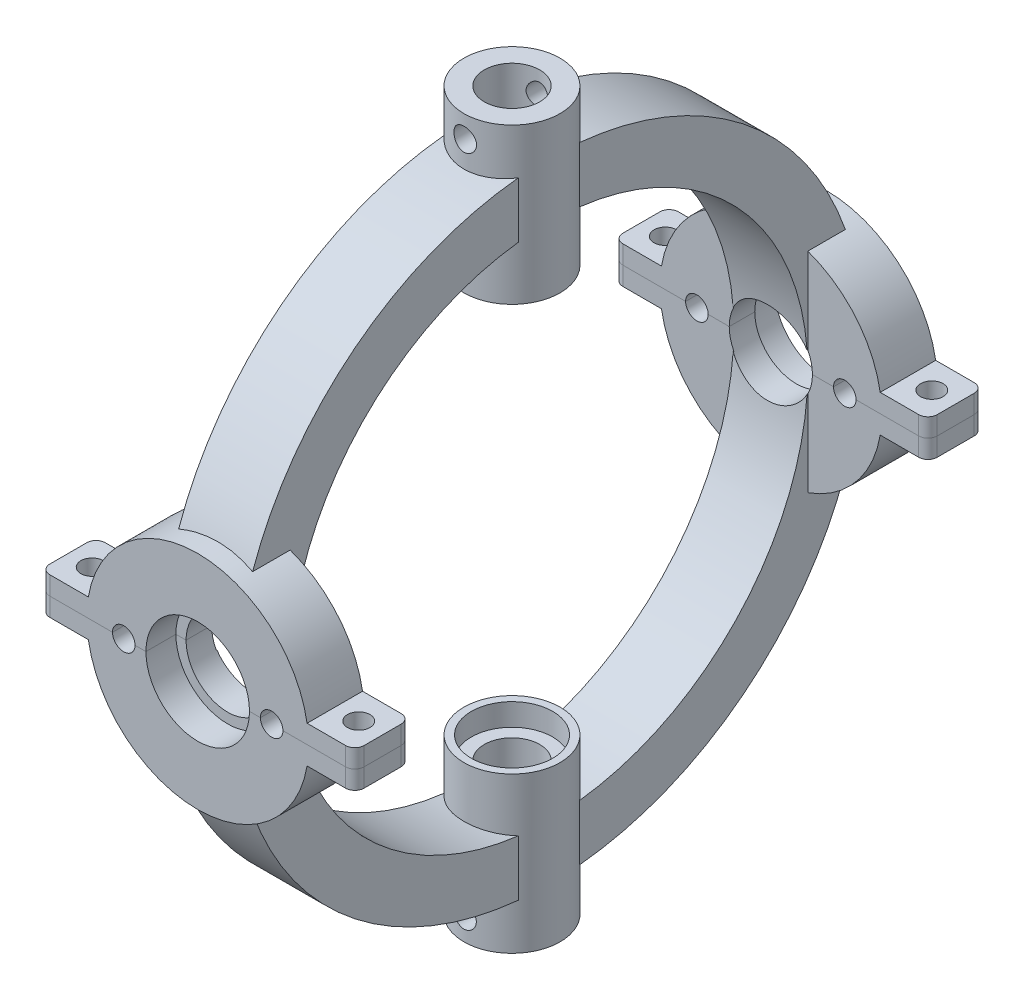
from build123d import *

# Parameters (mm, degrees)
SKETCH1_W                = 13
SKETCH1_H                = 150
SKETCH2_R                = 85
SKETCH2_R_2              = 70
BOSS_EXTRUDE1_DEPTH      = 10
BOSS_EXTRUDE1_DEPTH_BACK = 10
SKETCH3_R                = 30
BOSS_EXTRUDE2_DEPTH      = 15
CUT_EXTRUDE1_REACH       = 194.419
SKETCH4_R                = 11.25
SKETCH4_R_2              = 3.05
BOSS_EXTRUDE3_DEPTH      = 15
MIRROR3_COPY_1_DEPTH     = 15
SKETCH6_R                = 3.05
CUT_EXTRUDE2_DEPTH       = 10
MIRROR5_COPY_1_SKETCH_R  = 3.05
MIRROR5_COPY_1_DEPTH     = 10
FILLET1_R                = 2.5
SKETCH7_R                = 13
BOSS_EXTRUDE4_DEPTH      = 15
SKETCH10_R               = 14
CUT_EXTRUDE5_DEPTH       = 8.1
SKETCH12_R               = 13
CUT_EXTRUDE7_DEPTH       = 55
CUT_EXTRUDE7_DEPTH_BACK  = 55
SKETCH13_R               = 11
CUT_EXTRUDE8_DEPTH       = 6
SKETCH14_R               = 7.5
CUT_EXTRUDE9_DEPTH       = 175.204621196
SKETCH15_R               = 13
SKETCH15_R_2             = 7.5
BOSS_EXTRUDE6_DEPTH      = 12
SKETCH16_R               = 3
CUT_EXTRUDE10_DEPTH      = 136.794882217
CUT_EXTRUDE10_DEPTH_BACK = 136.794882217
SKETCH17_R               = 13
SKETCH17_R_2             = 7.5
BOSS_EXTRUDE7_DEPTH      = 12
SKETCH18_R               = 3.05
CUT_EXTRUDE11_DEPTH      = 136.794882217
CUT_EXTRUDE11_DEPTH_BACK = 136.794882217


with BuildPart() as part:
    # Sketch1 → Revolve1 (revolve)
    with BuildSketch(Plane(origin=(0, 0, 0), x_dir=(0, 0, -1), z_dir=(1, 0, 0))):
        with Locations((6.5, 0)):
            Rectangle(SKETCH1_W, SKETCH1_H)
    revolve(axis=Axis((0, -75, 0), (0, 1, 0)))

    # Sketch2 → Boss-Extrude1 (add, two sides)
    with BuildSketch(Plane(origin=(0, 0, 0), x_dir=(0, 0, -1), z_dir=(1, 0, 0))) as boss_extrude1_sk:
        Circle(SKETCH2_R)
        Circle(SKETCH2_R_2, mode=Mode.SUBTRACT)
    extrude(amount=BOSS_EXTRUDE1_DEPTH)
    extrude(boss_extrude1_sk.sketch, amount=-BOSS_EXTRUDE1_DEPTH_BACK)

    # Sketch3 → Boss-Extrude2 (add)
    with BuildSketch(Plane.XY.offset(85)):
        Circle(SKETCH3_R)
    boss_extrude2 = extrude(amount=-BOSS_EXTRUDE2_DEPTH)

    # Sketch4 → Cut-Extrude1 (cut, up to next)
    with BuildSketch(Plane.XY.offset(85), mode=Mode.PRIVATE) as cut_extrude1_sk1:
        Circle(SKETCH4_R)
    cut_extrude1_tool1 = extrude(cut_extrude1_sk1.sketch, amount=-CUT_EXTRUDE1_REACH, mode=Mode.PRIVATE) & part.part
    # Sketch4 → Cut-Extrude1 (cut, up to next)
    with BuildSketch(Plane.XY.offset(85), mode=Mode.PRIVATE) as cut_extrude1_sk2:
        with Locations((20, 0)):
            Circle(SKETCH4_R_2)
    cut_extrude1_tool2 = extrude(cut_extrude1_sk2.sketch, amount=-CUT_EXTRUDE1_REACH, mode=Mode.PRIVATE) & part.part
    # Sketch4 → Cut-Extrude1 (cut, up to next)
    with BuildSketch(Plane.XY.offset(85), mode=Mode.PRIVATE) as cut_extrude1_sk3:
        with Locations((-20, 0)):
            Circle(SKETCH4_R_2)
    cut_extrude1_tool3 = extrude(cut_extrude1_sk3.sketch, amount=-CUT_EXTRUDE1_REACH, mode=Mode.PRIVATE) & part.part
    cut_extrude1_1 = cut_extrude1_tool1.solids().sort_by_distance((0, 0, 85))[0]
    add(cut_extrude1_1, mode=Mode.SUBTRACT)
    cut_extrude1_2 = cut_extrude1_tool2.solids().sort_by_distance((20, 0, 85))[0]
    add(cut_extrude1_2, mode=Mode.SUBTRACT)
    cut_extrude1_3 = cut_extrude1_tool3.solids().sort_by_distance((-20, 0, 85))[0]
    add(cut_extrude1_3, mode=Mode.SUBTRACT)
    cut_extrude1 = cut_extrude1_1 + cut_extrude1_2 + cut_extrude1_3  # Cut-Extrude1 as one shape, for the pattern or mirror that repeats it

    # Mirror1: Boss-Extrude2, Cut-Extrude1 across plane
    add(boss_extrude2.mirror(Plane.XY))
    add(cut_extrude1.mirror(Plane.XY), mode=Mode.SUBTRACT)

    # Sketch5 → Boss-Extrude3 (add)
    with BuildSketch(Plane.XY.offset(85)):
        Polygon((-42.5, 0), (-42.5, 5), (-27.5, 5), (-27.5, -5), (-42.5, -5), align=None)
    boss_extrude3 = extrude(amount=-BOSS_EXTRUDE3_DEPTH)

    # Mirror2: Boss-Extrude3 across plane
    add(boss_extrude3.mirror(Plane(origin=(0, 0, 0), x_dir=(0, 0, 1), z_dir=(1, 0, 0))))

    # Mirror3: Boss-Extrude3 across plane
    add(boss_extrude3.mirror(Plane.XY))

    # Mirror3 copy 1 sketch → Mirror3 copy 1 (add)
    with BuildSketch(Plane(origin=(0, 0, -85), x_dir=(-1, 0, 0), z_dir=(0, 0, -1))):
        Polygon((-42.5, 0), (-42.5, 5), (-27.5, 5), (-27.5, -5), (-42.5, -5), align=None)
    extrude(amount=-MIRROR3_COPY_1_DEPTH)

    # Sketch6 → Cut-Extrude2 (cut)
    with BuildSketch(Plane(origin=(0, 5, 0), x_dir=(1, 0, 0), z_dir=(0, 1, 0))):
        with Locations(Location((-36.040199458, -77.5, 0), (0, 0, 180))):
            Circle(SKETCH6_R)
    cut_extrude2 = extrude(amount=-CUT_EXTRUDE2_DEPTH, mode=Mode.SUBTRACT)

    # Mirror4: Cut-Extrude2 across plane
    add(cut_extrude2.mirror(Plane(origin=(0, 0, 0), x_dir=(0, 0, 1), z_dir=(1, 0, 0))), mode=Mode.SUBTRACT)

    # Mirror5: Cut-Extrude2 across plane
    add(cut_extrude2.mirror(Plane.XY), mode=Mode.SUBTRACT)

    # Mirror5 copy 1 sketch → Mirror5 copy 1 (cut)
    with BuildSketch(Plane(origin=(0, 5, 0), x_dir=(-1, 0, 0), z_dir=(0, 1, 0))):
        with Locations(Location((-36.040199458, -77.5, 0), (0, 0, 180))):
            Circle(MIRROR5_COPY_1_SKETCH_R)
    extrude(amount=-MIRROR5_COPY_1_DEPTH, mode=Mode.SUBTRACT)

    # Fillet1
    fillet1_edges = [part.edges().sort_by_distance(p)[0] for p in [
        (-42.5, 0, 70),
        (-42.5, 0, 85),
        (42.5, 0, 85),
        (42.5, 0, 70),
        (-42.5, 0, -85),
        (-42.5, 0, -70),
        (42.5, 0, -70),
        (42.5, 0, -85),
    ]]
    fillet(fillet1_edges, radius=FILLET1_R)

    # Sketch7 → Boss-Extrude4 (add)
    with BuildSketch(Plane(origin=(0, -85, 0), x_dir=(-1, 0, 0), z_dir=(0, -1, 0))):
        with Locations(Location((0, 0, 0), (0, 0, 90))):
            Circle(SKETCH7_R)
    boss_extrude4 = extrude(amount=-BOSS_EXTRUDE4_DEPTH)

    # Mirror6: Boss-Extrude4 across plane
    add(boss_extrude4.mirror(Plane.ZX))

    # Sketch10 → Cut-Extrude5 (cut)
    with BuildSketch(Plane.XY.offset(85)):
        Circle(SKETCH10_R)
    cut_extrude5 = extrude(amount=-CUT_EXTRUDE5_DEPTH, mode=Mode.SUBTRACT)

    # Mirror9: Cut-Extrude5 across plane
    add(cut_extrude5.mirror(Plane.XY), mode=Mode.SUBTRACT)

    # Sketch12 → Cut-Extrude7 (cut, two sides)
    with BuildSketch(Plane(origin=(0, 0, 0), x_dir=(1, 0, 0), z_dir=(0, 1, 0))) as cut_extrude7_sk:
        with Locations(Location((0, 0, 0), (0, 0, 90))):
            Circle(SKETCH12_R)
    extrude(amount=CUT_EXTRUDE7_DEPTH, mode=Mode.SUBTRACT)
    extrude(cut_extrude7_sk.sketch, amount=-CUT_EXTRUDE7_DEPTH_BACK, mode=Mode.SUBTRACT)

    # Sketch13 → Cut-Extrude8 (cut)
    with BuildSketch(Plane.XZ.offset(-55)):
        with Locations(Location((0, 0, 0), (0, 0, 270))):
            Circle(SKETCH13_R)
    cut_extrude8 = extrude(amount=-CUT_EXTRUDE8_DEPTH, mode=Mode.SUBTRACT)

    # Sketch14 → Cut-Extrude9 (cut, through all)
    with BuildSketch(Plane.XZ.offset(-61)):
        with Locations(Location((0, 0, 0), (0, 0, 270))):
            Circle(SKETCH14_R)
    cut_extrude9 = extrude(amount=-CUT_EXTRUDE9_DEPTH, mode=Mode.SUBTRACT)

    # Mirror11: Cut-Extrude8, Cut-Extrude9 across plane
    add(cut_extrude8.mirror(Plane.ZX), mode=Mode.SUBTRACT)
    add(cut_extrude9.mirror(Plane.ZX), mode=Mode.SUBTRACT)

    # Sketch15 → Boss-Extrude6 (add)
    with BuildSketch(Plane.XZ.offset(85)):
        with Locations(Location((0, 0, 0), (0, 0, 270))):
            Circle(SKETCH15_R)
        with Locations(Location((0, 0, 0), (0, 0, 270))):
            Circle(SKETCH15_R_2, mode=Mode.SUBTRACT)
    extrude(amount=BOSS_EXTRUDE6_DEPTH)

    # Sketch16 → Cut-Extrude10 (cut, two sides)
    with BuildSketch(Plane.XY) as cut_extrude10_sk:
        with Locations(Location((0, -91, 0), (0, 0, 270))):
            Circle(SKETCH16_R)
    extrude(amount=CUT_EXTRUDE10_DEPTH, mode=Mode.SUBTRACT)
    extrude(cut_extrude10_sk.sketch, amount=-CUT_EXTRUDE10_DEPTH_BACK, mode=Mode.SUBTRACT)

    # Sketch17 → Boss-Extrude7 (add)
    with BuildSketch(Plane(origin=(0, 85, 0), x_dir=(1, 0, 0), z_dir=(0, 1, 0))):
        with Locations(Location((0, 0, 0), (0, 0, 90))):
            Circle(SKETCH17_R)
        with Locations(Location((0, 0, 0), (0, 0, 90))):
            Circle(SKETCH17_R_2, mode=Mode.SUBTRACT)
    extrude(amount=BOSS_EXTRUDE7_DEPTH)

    # Sketch18 → Cut-Extrude11 (cut, two sides)
    with BuildSketch(Plane.XY) as cut_extrude11_sk:
        with Locations((0, 91)):
            Circle(SKETCH18_R)
    extrude(amount=CUT_EXTRUDE11_DEPTH, mode=Mode.SUBTRACT)
    extrude(cut_extrude11_sk.sketch, amount=-CUT_EXTRUDE11_DEPTH_BACK, mode=Mode.SUBTRACT)


with BuildPart() as body_2:
    # Split1: the piece on the far side of the plane
    add(part.part)
    split(bisect_by=Plane.ZX, keep=Keep.BOTTOM)


with BuildPart() as part_1:
    add(part.part)

    # Split1
    split(bisect_by=Plane.ZX, keep=Keep.TOP)


solid = Compound([body_2.part, part_1.part])
